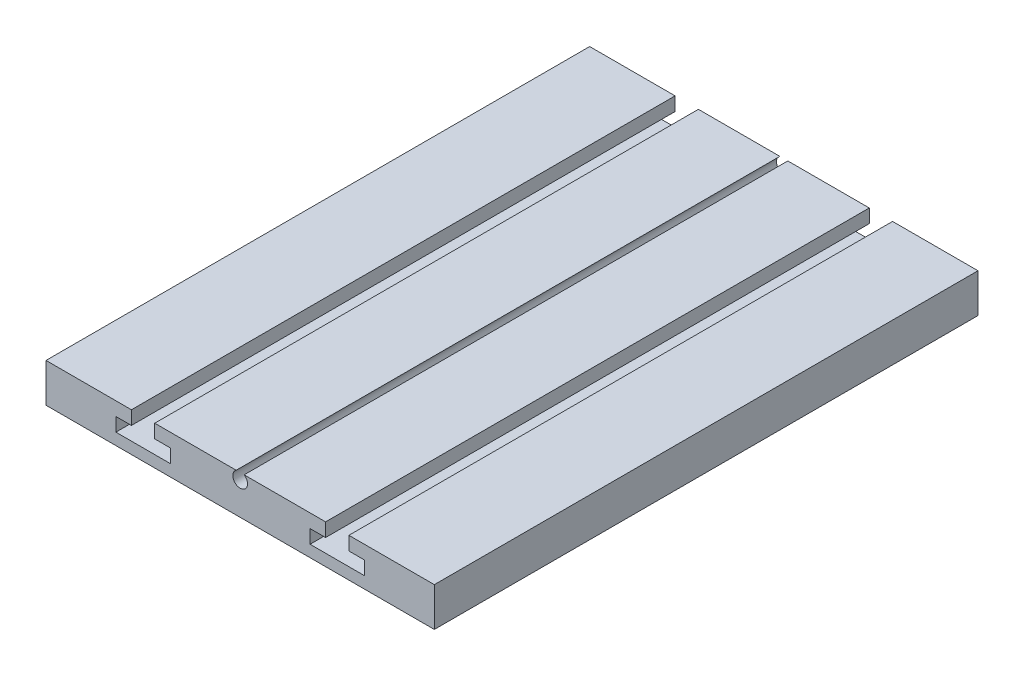
from build123d import *

# Parameters (mm, degrees)
SKETCH1_W           = 50
SKETCH1_H           = 5
BOSS_EXTRUDE1_DEPTH = 70
SKETCH3_R           = 0.95
CUT_EXTRUDE2_DEPTH  = 71


with BuildPart() as part:
    # Sketch1 → Boss-Extrude1 (new body)
    with BuildSketch(Plane.XY):
        with Locations((25, 2.5)):
            Rectangle(SKETCH1_W, SKETCH1_H)
    extrude(amount=BOSS_EXTRUDE1_DEPTH)

    # Sketch3 → Cut-Extrude2 (cut, through all)
    with BuildSketch(Plane.XY.offset(70)):
        with Locations((25, 4.2)):
            Circle(SKETCH3_R)
        Polygon((14, 3.25), (16, 3.25), (16, 1.5), (9, 1.5), (9, 3.25), (11, 3.25), (11, 5), (14, 5), align=None)
        Polygon((41, 3.25), (41, 1.5), (34, 1.5), (34, 3.25), (36, 3.25), (36, 5), (39, 5), (39, 3.25), align=None)
    extrude(amount=-CUT_EXTRUDE2_DEPTH, mode=Mode.SUBTRACT)


solid = part.part
